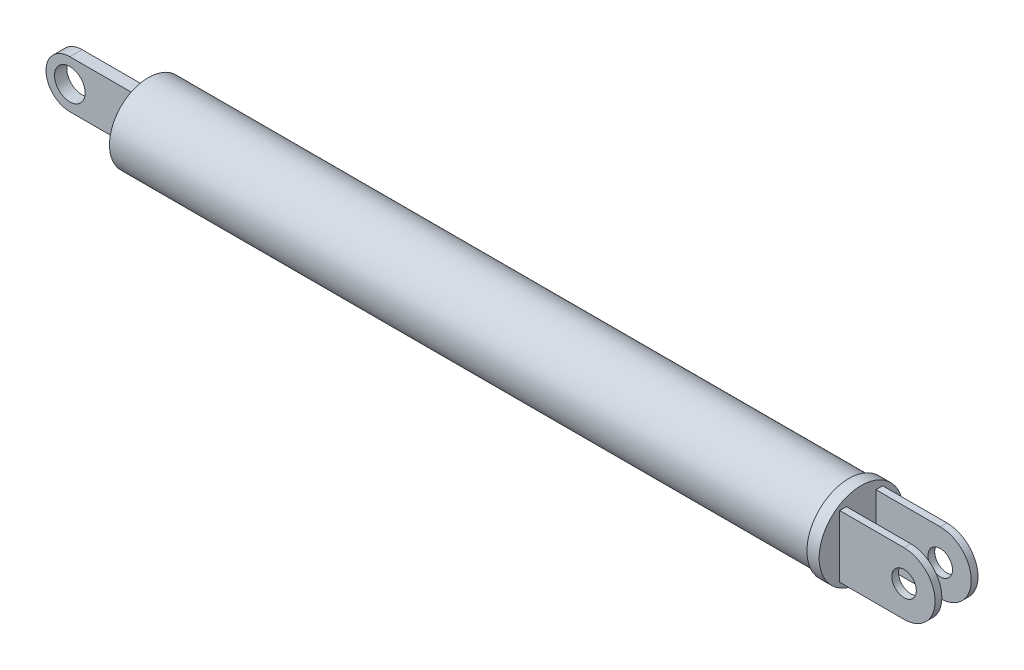
from build123d import *

# Parameters (mm, degrees)
SKETCH1_R               = 12.7
EXTRUDE1_DEPTH          = 228.6
SKETCH2_R               = 5
EXTRUDE2_DEPTH          = 2
SKETCH3_R               = 13.7
EXTRUDE3_DEPTH          = 4
SKETCH4_R               = 4
EXTRUDE4_DEPTH          = 7
CUT_EXTRUDE1_DEPTH      = 265.443561427
CUT_EXTRUDE1_DEPTH_BACK = 265.443561427
SKETCH5_W               = 127.127972269
SKETCH5_H               = 9.602426348


with BuildPart() as part:
    # Sketch1 → Extrude1 (new body)
    with BuildSketch(Plane(origin=(0, 0, 0), x_dir=(0, 0, -1), z_dir=(1, 0, 0))):
        Circle(SKETCH1_R)
    extrude(amount=EXTRUDE1_DEPTH)

    # Sketch2 → Extrude2 (add, symmetric)
    with BuildSketch(Plane.XY):
        with BuildLine():
            Line((0, 7.778067586), (-23.625125491, 7.778067586))
            ThreePointArc((-23.625125491, 7.778067586), (-31.403193077, 0), (-23.625125491, -7.778067586))
            Line((-23.625125491, -7.778067586), (0, -7.778067586))
            Line((0, -7.778067586), (0, 7.778067586))
        make_face()
        with Locations((-23.625125491, 0)):
            Circle(SKETCH2_R, mode=Mode.SUBTRACT)
    extrude(amount=EXTRUDE2_DEPTH, both=True)

    # Sketch3 → Extrude3 (add)
    with BuildSketch(Plane(origin=(228.6, 0, 0), x_dir=(0, 0, -1), z_dir=(1, 0, 0))):
        Circle(SKETCH3_R)
    extrude(amount=EXTRUDE3_DEPTH)

    # Sketch4 → Extrude4 (add, symmetric)
    with BuildSketch(Plane.XY):
        with BuildLine():
            Line((232.6, 10.132851916), (253.6, 10.132851916))
            ThreePointArc((253.6, 10.132851916), (263.732851916, 0), (253.6, -10.132851916))
            Line((253.6, -10.132851916), (232.6, -10.132851916))
            Line((232.6, -10.132851916), (232.6, 10.132851916))
        make_face()
        with Locations((253.6, 0)):
            Circle(SKETCH4_R, mode=Mode.SUBTRACT)
    extrude(amount=EXTRUDE4_DEPTH, both=True)

    # Sketch5 → Cut-Extrude1 (cut, two sides: drawn at the far end of the back side and taken through both)
    with BuildSketch(Plane(origin=(0, 0, 0), x_dir=(1, 0, 0), z_dir=(0, 1, 0)).offset(-CUT_EXTRUDE1_DEPTH_BACK)):
        with Locations((296.163986135, 0)):
            Rectangle(SKETCH5_W, SKETCH5_H)
    extrude(amount=CUT_EXTRUDE1_DEPTH + CUT_EXTRUDE1_DEPTH_BACK, mode=Mode.SUBTRACT)


solid = part.part
